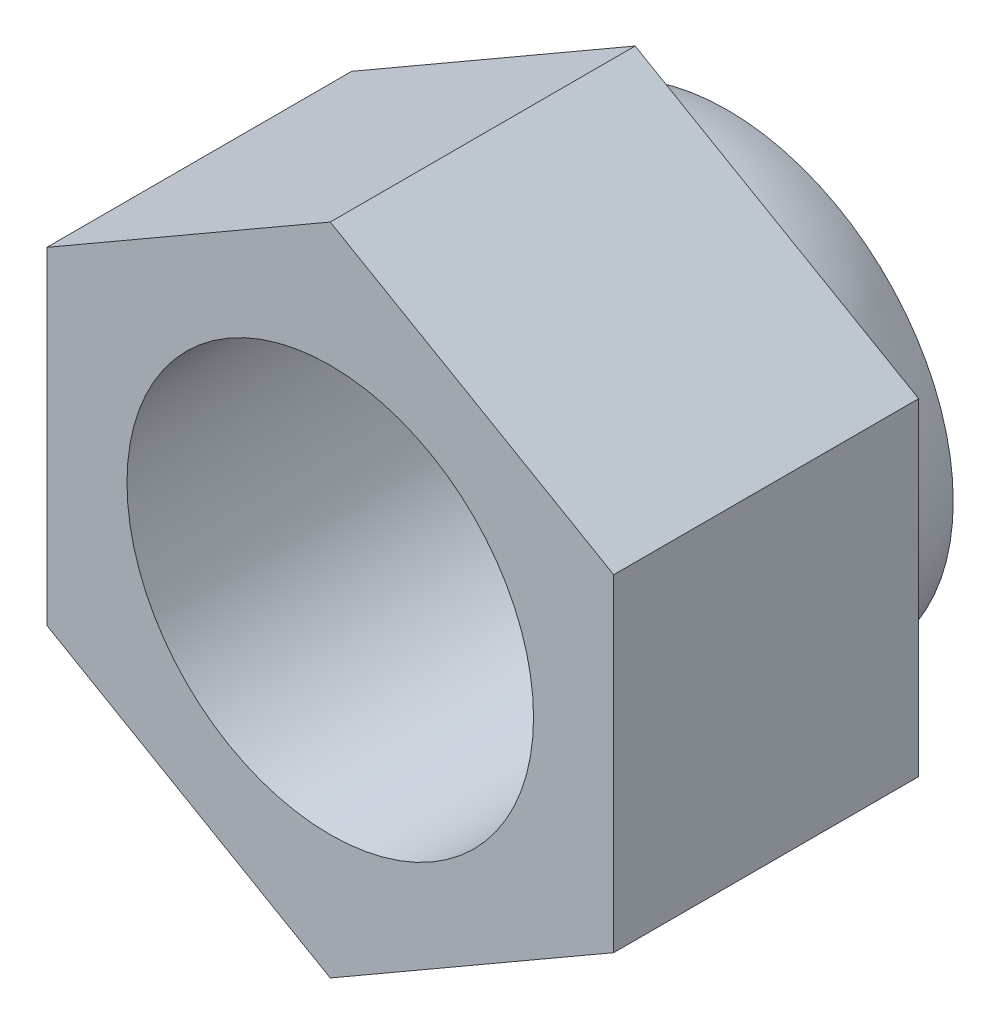
from build123d import *

# Parameters (mm, degrees)
SKETCH_1_R          = 1
EXTRUDE_1_DEPTH     = 1.5
CUT_EXTRUDE_START   = -1.5
SKETCH_4_R          = 1
CUT_EXTRUDE_1_DEPTH = 1.5
SKETCH_5_W          = 4.342397196
SKETCH_5_H          = 0.669337657
CUT_EXTRUDE_2_DEPTH = 4.816736312
FILLET_1_R          = 0.1


with BuildPart() as part:
    # 草图1 → 凸台-拉伸1 (new body)
    with BuildSketch(Plane.XY):
        Polygon((0, 1.610326941), (-1.394584039, 0.805163471), (-1.394584039, -0.805163471), (0, -1.610326941), (1.394584039, -0.805163471), (1.394584039, 0.805163471), align=None)
        Circle(SKETCH_1_R, mode=Mode.SUBTRACT)
    extrude(amount=EXTRUDE_1_DEPTH)

    # 草图3 → 旋转1 (revolve)
    with BuildSketch(Plane(origin=(0, 0, 0), x_dir=(1, 0, 0), z_dir=(0, 1, 0))):
        with BuildLine():
            Line((0, 0), (-1.2, 0))
            ThreePointArc((-1.2, 0), (-0.848528137, 0.848528137), (0, 1.2))
            Line((0, 1.2), (0, 0))
        make_face()
    revolve(axis=Axis((0, 0, 0), (0, 0, -1)))

    # 草图4 → 切除-拉伸1 (cut)
    with BuildSketch(Plane.XY.offset(CUT_EXTRUDE_START)):
        Circle(SKETCH_4_R)
    extrude(amount=CUT_EXTRUDE_1_DEPTH, mode=Mode.SUBTRACT)

    # 草图5 → 切除-拉伸2 (cut, through all)
    with BuildSketch(Plane(origin=(-0.69729202, 1.207745206, 0), x_dir=(0.8660254037844382, 0.5000000000000009, 0), z_dir=(-0.5000000000000009, 0.8660254037844383, 0))):
        with Locations((0.228359132, 0.788550397)):
            Rectangle(SKETCH_5_W, SKETCH_5_H)
    extrude(amount=-CUT_EXTRUDE_2_DEPTH, mode=Mode.SUBTRACT)

    # 圆角1
    fillet_1_edges = [part.edges().sort_by_distance(p)[0] for p in [
        (1.2, 0, 0),
    ]]
    fillet(fillet_1_edges, radius=FILLET_1_R)


solid = part.part
